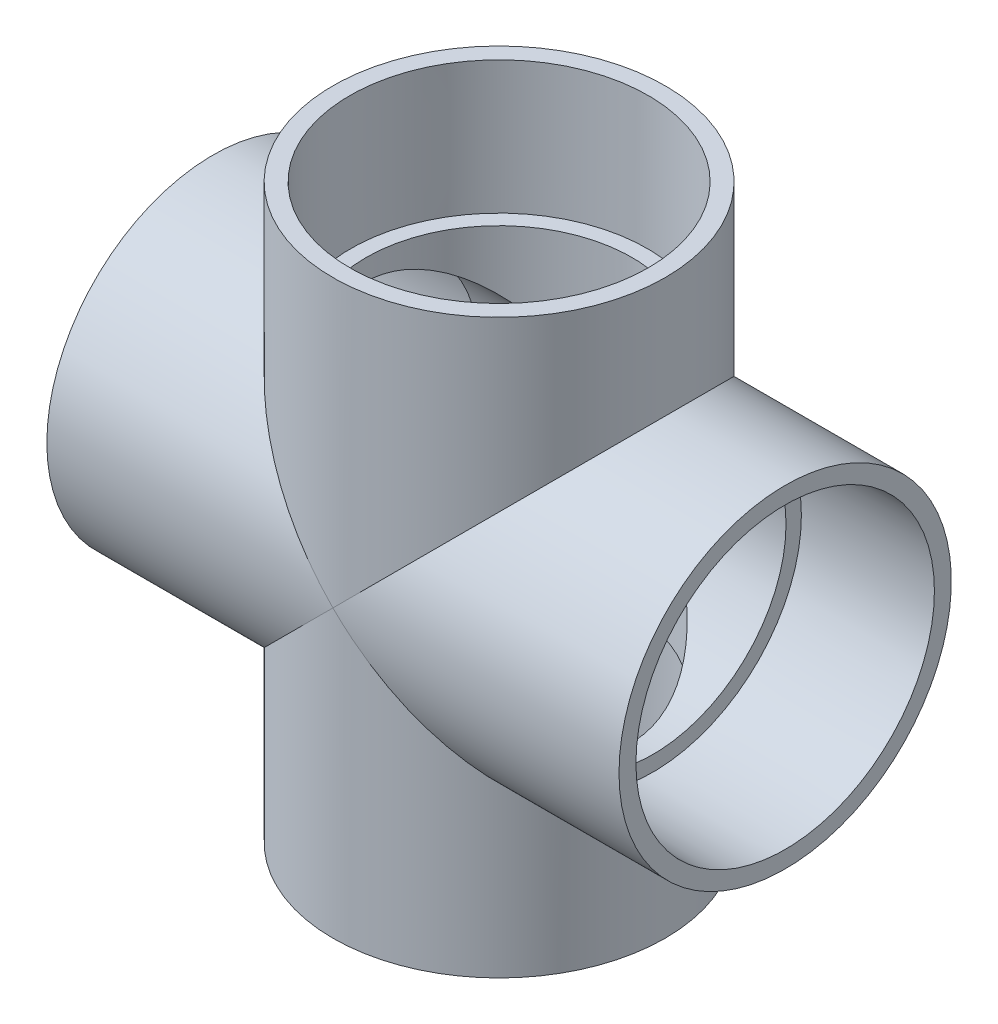
from build123d import *

# Parameters (mm, degrees)
SKETCH4_R           = 63.881
BOSS_EXTRUDE1_DEPTH = 169.164
SKETCH5_R           = 63.881
BOSS_EXTRUDE2_DEPTH = 169.164


with BuildPart() as part:
    # Sketch1 → Revolve1 (revolve)
    with BuildSketch(Plane.XY):
        Polygon((-109.982, -63.881), (-59.182, -63.881), (-59.182, -57.0357), (-109.982, -57.3786), align=None)
        Polygon((109.982, -57.3786), (59.182, -57.0357), (59.182, -63.881), (109.982, -63.881), align=None)
    revolve(axis=Axis((-109.982, 0, 0), (1, 0, 0)))



with BuildPart() as body_2:
    # Sketch2 → Revolve2 (revolve)
    with BuildSketch(Plane.XY):
        Polygon((57.3786, 109.982), (57.0357, 59.182), (63.881, 59.182), (63.881, 109.982), align=None)
        Polygon((63.881, -109.982), (57.3786, -109.982), (57.0357, -59.182), (63.881, -59.182), align=None)
    revolve(axis=Axis((0, 0, 0), (0, 1, 0)))


with BuildPart() as part_1:
    add(part.part)

    add(body_2.part)  # Boss-Extrude1 merges body 2
    # Sketch4 → Boss-Extrude1 (add)
    with BuildSketch(Plane(origin=(-59.182, 0, 0), x_dir=(0, 0, -1), z_dir=(1, 0, 0))):
        Circle(SKETCH4_R)
    extrude(amount=BOSS_EXTRUDE1_DEPTH)

    # Sketch5 → Boss-Extrude2 (add)
    with BuildSketch(Plane.XZ.offset(-59.182)):
        Circle(SKETCH5_R)
    extrude(amount=BOSS_EXTRUDE2_DEPTH)

    # Sketch6 → Cut-Revolve1 (revolve, cut)
    with BuildSketch(Plane.XY):
        Polygon((-109.982, -57.3786), (-59.182, -57.0357), (-59.182, -51.1302), (59.182, -51.1302), (59.182, -57.0357), (109.982, -57.3786), (109.982, 0), (-109.982, 0), align=None)
    revolve(axis=Axis((109.982, 0, 0), (-1, 0, 0)), mode=Mode.SUBTRACT)

    # Sketch7 → Cut-Revolve2 (revolve, cut)
    with BuildSketch(Plane.XY):
        Polygon((57.3786, 109.982), (57.0357, 59.182), (51.1302, 59.182), (51.1302, -59.182), (57.0357, -59.182), (57.3786, -109.982), (0, -109.982), (0, 109.982), align=None)
    revolve(axis=Axis((0, 109.982, 0), (0, -1, 0)), mode=Mode.SUBTRACT)


solid = part_1.part
